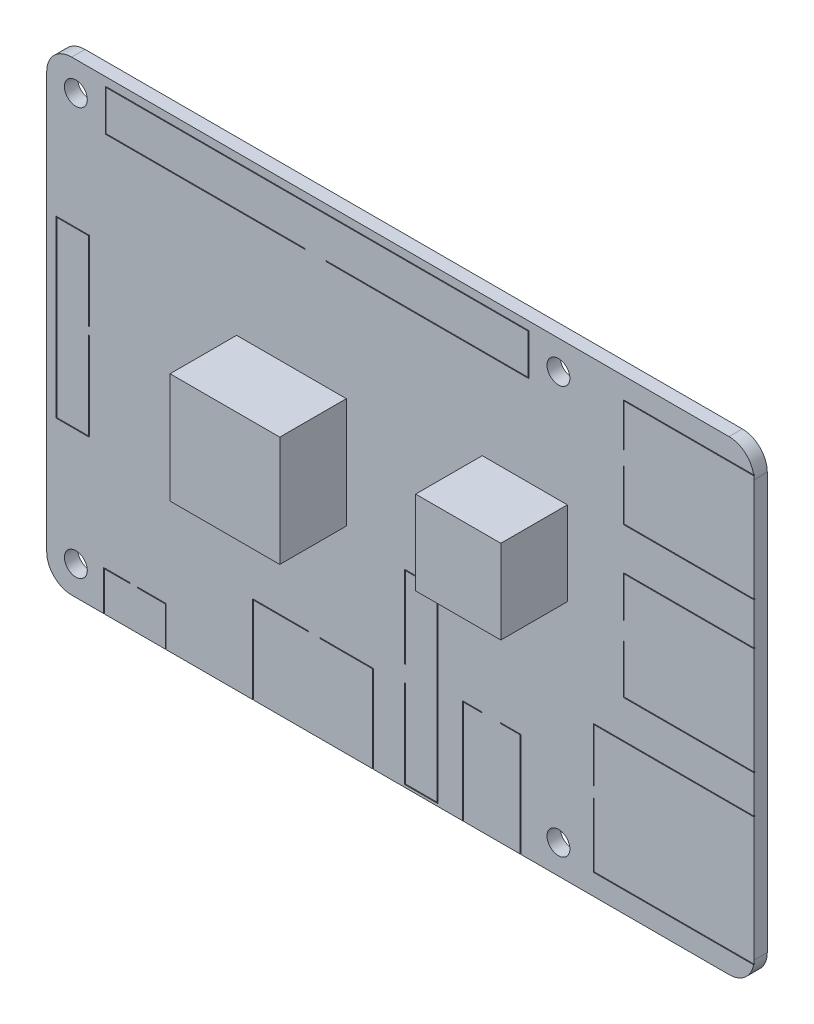
from build123d import *

# Parameters (mm, degrees)
SKETCH1_R           = 1.375
BOSS_EXTRUDE1_DEPTH = 1.6
CUT_EXTRUDE1_DEPTH  = 0.1
SKETCH_1_W          = 13.191380008
SKETCH_1_H          = 13.254567414
EXTRUDE_1_DEPTH     = 8
SKETCH_2_W          = 10.236154205
SKETCH_2_H          = 10.074954926
EXTRUDE_2_DEPTH     = 8


with BuildPart() as part:
    # Sketch1 → Boss-Extrude1 (new body)
    with BuildSketch(Plane.XY):
        with BuildLine():
            Line((-39.5, -28), (39.5, -28))
            ThreePointArc((39.5, -28), (41.621320344, -27.121320344), (42.5, -25))
            Line((42.5, -25), (42.5, 25))
            ThreePointArc((42.5, 25), (41.621320344, 27.121320344), (39.5, 28))
            Line((39.5, 28), (-39.5, 28))
            ThreePointArc((-39.5, 28), (-41.621320344, 27.121320344), (-42.5, 25))
            Line((-42.5, 25), (-42.5, -25))
            ThreePointArc((-42.5, -25), (-41.621320344, -27.121320344), (-39.5, -28))
        make_face()
        with Locations((-39, 24.5)):
            Circle(SKETCH1_R, mode=Mode.SUBTRACT)
        with Locations((-39, -24.5)):
            Circle(SKETCH1_R, mode=Mode.SUBTRACT)
        with Locations((19, 24.5)):
            Circle(SKETCH1_R, mode=Mode.SUBTRACT)
        with Locations((19, -24.5)):
            Circle(SKETCH1_R, mode=Mode.SUBTRACT)
    extrude(amount=BOSS_EXTRUDE1_DEPTH)

    # Sketch2 → Cut-Extrude1 (cut)
    with BuildSketch(Plane.XY.offset(1.6)):
        Polygon((-35.65, -28.636850855), (-28.15, -28.636850855), (-28.15, -23.2), (-31.573707352, -23.2), (-31.573707352, -23.3), (-28.25, -23.3), (-28.25, -28.536850855), (-35.55, -28.536850855), (-35.55, -23.3), (-32.465045999, -23.3), (-32.465045999, -23.2), (-35.65, -23.2), align=None)
        Polygon((-17.75, -17.5), (-11.015830732, -17.5), (-11.015830732, -17.6), (-17.65, -17.6), (-17.65, -33.061376344), (-3.35, -33.061376344), (-3.35, -17.6), (-9.684859924, -17.6), (-9.684859924, -17.5), (-3.25, -17.5), (-3.25, -33.161376344), (-17.75, -33.161376344), align=None)
        Polygon((0.5, -5.3), (4.5, -5.3), (4.5, -27.7), (0.5, -27.7), (0.5, -17.125), (0.6, -17.125), (0.6, -27.6), (4.4, -27.6), (4.4, -5.4), (0.6, -5.4), (0.6, -15.17398131), (0.5, -15.17398131), align=None)
        Polygon((7.5, -15.5), (9.799158316, -15.5), (9.799158316, -15.6), (7.6, -15.6), (7.6, -31.061376344), (14.4, -31.061376344), (14.4, -15.6), (12.062610562, -15.6), (12.062610562, -15.5), (14.5, -15.5), (14.5, -31.161376344), (7.5, -31.161376344), align=None)
        Polygon((-35.45, 27), (15.45, 27), (15.45, 22), (-8.906687942, 22), (-8.906687942, 22.1), (15.35, 22.1), (15.35, 26.9), (-35.35, 26.9), (-35.35, 22.1), (-11.458179647, 22.1), (-11.458179647, 22), (-35.45, 22), align=None)
        Polygon((-41.371710411, -10.514157593), (-37.371710411, -10.514157593), (-37.371710411, 0.094714316), (-37.471710411, 0.094714316), (-37.471710411, -10.414157593), (-41.271710411, -10.414157593), (-41.271710411, 10.414157593), (-37.471710411, 10.414157593), (-37.471710411, 1), (-37.371710411, 1), (-37.371710411, 10.514157593), (-41.371710411, 10.514157593), align=None)
        Polygon((23.2, -25.5), (44.7, -25.5), (44.7, -10), (23.2, -10), (23.2, -16.5), (23.3, -16.5), (23.3, -10.1), (44.6, -10.1), (44.6, -25.4), (23.3, -25.4), (23.3, -17.75), (23.2, -17.75), align=None)
        Polygon((26.8, -5.5), (54.071370237, -5.5), (54.071370237, 7.5), (26.8, 7.5), (26.8, 2.552788505), (26.9, 2.552788505), (26.9, 7.4), (53.971370237, 7.4), (53.971370237, -5.4), (26.9, -5.4), (26.9, 0.407211154), (26.8, 0.407211154), align=None)
        Polygon((26.8, 12.5), (57.71374017, 12.5), (57.71374017, 25.5), (26.8, 25.5), (26.8, 20.277341759), (26.9, 20.277341759), (26.9, 25.4), (57.61374017, 25.4), (57.61374017, 12.6), (26.9, 12.6), (26.9, 18.611308355), (26.8, 18.611308355), align=None)
    extrude(amount=-CUT_EXTRUDE1_DEPTH, mode=Mode.SUBTRACT)

    # Эскиз1 → Бобышка-Вытянуть1 (add)
    with BuildSketch(Plane.XY.offset(1.6)):
        with Locations((-13.084710258, 2.32266466)):
            Rectangle(SKETCH_1_W, SKETCH_1_H)
    extrude(amount=EXTRUDE_1_DEPTH)

    # Эскиз2 → Бобышка-Вытянуть2 (add)
    with BuildSketch(Plane.XY.offset(1.6)):
        with Locations((14.958106781, 6.145819854)):
            Rectangle(SKETCH_2_W, SKETCH_2_H)
    extrude(amount=EXTRUDE_2_DEPTH)


solid = part.part
